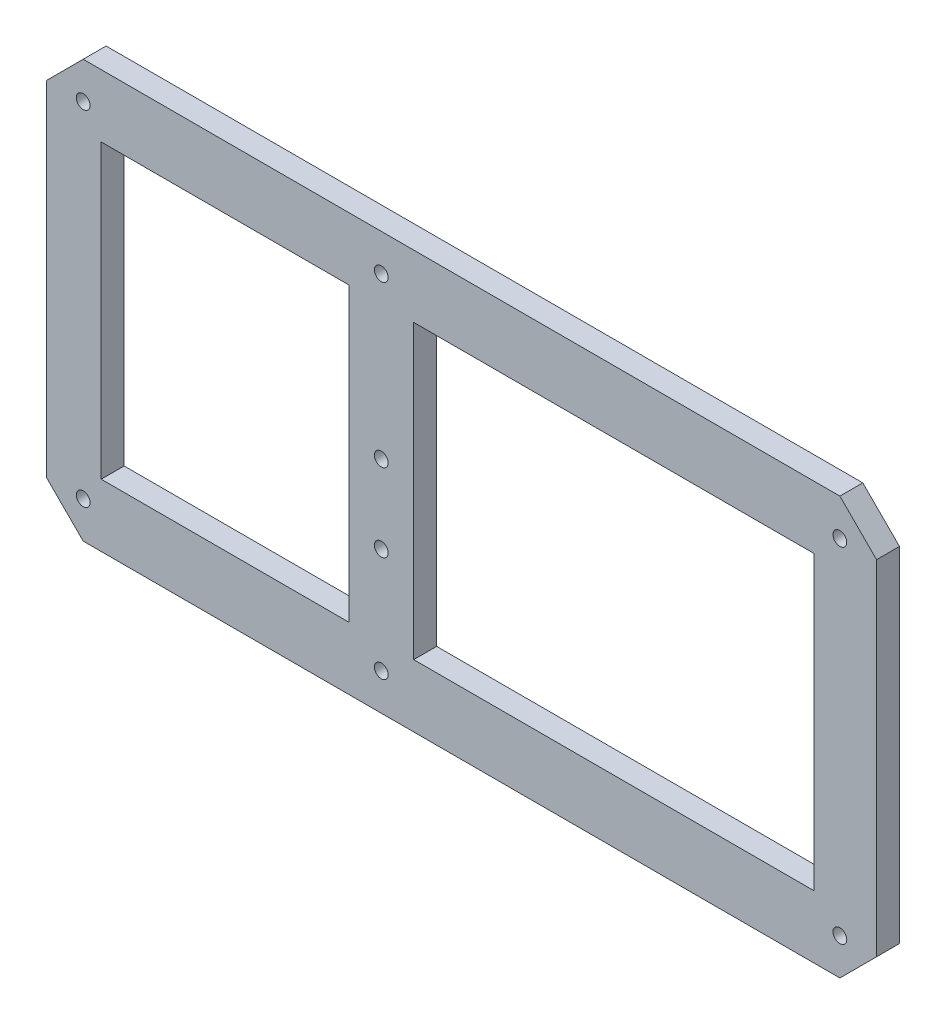
from build123d import *

# Parameters (mm, degrees)
SKETCH_1_R      = 1.5
EXTRUDE_1_DEPTH = 5


with BuildPart() as part:
    # 草图1 → 凸台-拉伸1 (new body)
    with BuildSketch(Plane.XY):
        Polygon((96.244173447, 49.032986466), (-3.755826553, 49.032986466), (-68.755826553, 49.032986466), (-76.755820543, 41.032992475), (-76.755820543, -33.967007525), (-68.755826553, -41.967013534), (96.244173447, -41.967013534), (104.244173447, -33.967013534), (104.244173447, 41.032986466), align=None)
        with Locations((-68.755826553, -33.967007525)):
            Circle(SKETCH_1_R, mode=Mode.SUBTRACT)
        with Locations((-3.755826553, -33.967013534)):
            Circle(SKETCH_1_R, mode=Mode.SUBTRACT)
        with Locations((-3.755826553, -10.967013534)):
            Circle(SKETCH_1_R, mode=Mode.SUBTRACT)
        with Locations((96.244173447, -33.967013534)):
            Circle(SKETCH_1_R, mode=Mode.SUBTRACT)
        Polygon((-64.826894365, -28.310159285), (-64.826894365, 35.376132216), (-10.826894365, 35.376132216), (-10.826894365, 28.305064404), (-10.826894365, -28.310159285), align=None, mode=Mode.SUBTRACT)
        with Locations((-3.755826553, 6.032986466)):
            Circle(SKETCH_1_R, mode=Mode.SUBTRACT)
        with Locations((-68.755826553, 41.032992475)):
            Circle(SKETCH_1_R, mode=Mode.SUBTRACT)
        with Locations((-3.755826553, 41.032986466)):
            Circle(SKETCH_1_R, mode=Mode.SUBTRACT)
        Polygon((90.587319198, -28.310159285), (3.315241259, -28.310159285), (3.315241259, 28.305064404), (3.315241259, 35.376132216), (90.587319198, 35.376132216), align=None, mode=Mode.SUBTRACT)
        with Locations((96.244173447, 41.032986466)):
            Circle(SKETCH_1_R, mode=Mode.SUBTRACT)
    extrude(amount=EXTRUDE_1_DEPTH)


solid = part.part
